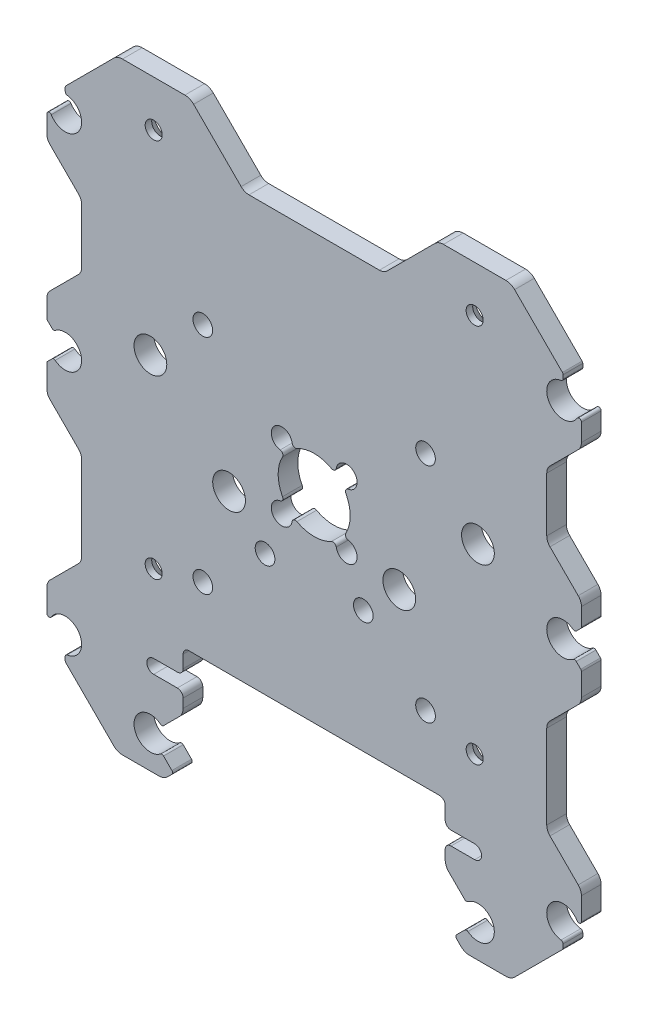
from build123d import *

# Parameters (mm, degrees)
BOSS_EXTRUDE1_DEPTH                            = 3
SKETCH2_W                                      = 21.308932188
SKETCH2_H                                      = 8.3
CUT_EXTRUDE1_DEPTH                             = 460.303275617
SKETCH3_W                                      = 5.3
SKETCH3_H                                      = 9.694178424
CUT_EXTRUDE2_DEPTH                             = 460.303275617
CUT_EXTRUDE3_DEPTH                             = 460.303275617
SKETCH5_W                                      = 5.3
SKETCH5_H                                      = 24.809178424
CUT_EXTRUDE4_DEPTH                             = 460.303275617
CUT_EXTRUDE5_DEPTH                             = 460.303275617
CUT_EXTRUDE6_DEPTH                             = 460.303275617
CUT_EXTRUDE7_DEPTH                             = 460.303275617
SKETCH9_W                                      = 5.3
SKETCH9_H                                      = 14.209178424
CUT_EXTRUDE8_DEPTH                             = 460.303275617
CUT_EXTRUDE9_DEPTH                             = 460.303275617
SKETCH11_W                                     = 5.3
SKETCH11_H                                     = 20.294178424
CUT_EXTRUDE10_DEPTH                            = 460.303275617
CUT_EXTRUDE11_DEPTH                            = 460.303275617
DRAFT1_ANGLE                                   = 45
DRAFT2_ANGLE                                   = 45
DRAFT3_ANGLE                                   = 45
DRAFT4_ANGLE                                   = 45
DRAFT5_ANGLE                                   = 45
DRAFT6_ANGLE                                   = 45
DRAFT7_ANGLE                                   = 45
DRAFT8_ANGLE                                   = 45
DRAFT9_ANGLE                                   = 45
SKETCH13_W                                     = 1.6
SKETCH13_H                                     = 3
SKETCH14_W                                     = 1.6
SKETCH14_H                                     = 3
SKETCH15_W                                     = 1.6
SKETCH15_H                                     = 3
SKETCH16_W                                     = 1.6
SKETCH16_H                                     = 3
SKETCH17_W                                     = 2.5
SKETCH17_H                                     = 3
SKETCH18_W                                     = 2.5
SKETCH18_H                                     = 3
CSK_FOR_M2_FLAT_HEAD_MACHINE_SCREW1_AT_2_COUNT = 2
CSK_FOR_M2_FLAT_HEAD_MACHINE_SCREW1_AT_2_PITCH = 49
CSK_FOR_M2_FLAT_HEAD_MACHINE_SCREW1_AT_3_COUNT = 2
CSK_FOR_M2_FLAT_HEAD_MACHINE_SCREW1_AT_3_PITCH = 75.927597091
CSK_FOR_M2_FLAT_HEAD_MACHINE_SCREW1_AT_4_COUNT = 2
CSK_FOR_M2_FLAT_HEAD_MACHINE_SCREW1_AT_4_PITCH = 58
F_3_0_3_DIAMETER_HOLE1_D                       = 3
F_5_0_5_DIAMETER_HOLE1_D                       = 5
FILLET1_R                                      = 0.36
FILLET2_R                                      = 0.89
FILLET3_R                                      = 1.69
FILLET4_R                                      = 1.89


with BuildPart() as part:
    # Sketch1 → Boss-Extrude1 (new body)
    with BuildSketch(Plane.XY.offset(3)):
        with BuildLine():
            Line((252.38239682, 372.890142644), (252.38239682, 373.92567655))
            Line((252.38239682, 373.92567655), (244.427930726, 381.880142644))
            Line((244.427930726, 381.880142644), (184.336862914, 381.880142644))
            Line((184.336862914, 381.880142644), (176.38239682, 373.92567655))
            Line((176.38239682, 373.92567655), (176.38239682, 372.890142645))
            ThreePointArc((176.38239682, 372.890142645), (178.563043816, 369.167531226), (174.249529687, 369.085965588))
            ThreePointArc((174.249529687, 369.085965588), (173.844846402, 369.244695355), (173.58239682, 368.898164092))
            Line((173.58239682, 368.898164092), (173.58239682, 302.862121197))
            ThreePointArc((173.58239682, 302.862121197), (173.844846402, 302.515589934), (174.249529687, 302.674319701))
            ThreePointArc((174.249529687, 302.674319701), (174.201749824, 300.147531226), (176.38239682, 298.870142644))
            Line((176.38239682, 298.870142644), (176.38239682, 297.834608739))
            Line((176.38239682, 297.834608739), (184.336862914, 289.880142644))
            Line((184.336862914, 289.880142644), (244.427930726, 289.880142644))
            Line((244.427930726, 289.880142644), (252.38239682, 297.834608739))
            Line((252.38239682, 297.834608739), (252.38239682, 298.870142644))
            ThreePointArc((252.38239682, 298.870142644), (250.201749824, 302.592754063), (254.515263953, 302.674319701))
            ThreePointArc((254.515263953, 302.674319701), (254.919947237, 302.515589934), (255.18239682, 302.862121197))
            Line((255.18239682, 302.862121197), (255.18239682, 368.898164092))
            ThreePointArc((255.18239682, 368.898164092), (254.919947237, 369.244695355), (254.515263953, 369.085965588))
            ThreePointArc((254.515263953, 369.085965588), (254.563043816, 371.612754063), (252.38239682, 372.890142644))
        make_face()
    extrude(amount=-BOSS_EXTRUDE1_DEPTH)

    # Sketch2 → Cut-Extrude1 (cut, through all)
    with BuildSketch(Plane(origin=(0, 0, 0), x_dir=(-1, 0, 0), z_dir=(0, 0, -1))):
        with Locations((-214.38239682, 377.730142644)):
            Rectangle(SKETCH2_W, SKETCH2_H)
    extrude(amount=-CUT_EXTRUDE1_DEPTH, mode=Mode.SUBTRACT)

    # Sketch3 → Cut-Extrude2 (cut, through all)
    with BuildSketch(Plane(origin=(0, 0, 0), x_dir=(-1, 0, 0), z_dir=(0, 0, -1))):
        with Locations((-176.23239682, 355.36871181)):
            Rectangle(SKETCH3_W, SKETCH3_H)
    extrude(amount=-CUT_EXTRUDE2_DEPTH, mode=Mode.SUBTRACT)

    # Sketch4 → Cut-Extrude3 (cut, through all)
    with BuildSketch(Plane(origin=(0, 0, 0), x_dir=(-1, 0, 0), z_dir=(0, 0, -1))):
        Polygon((-173.58239682, 336.090142644), (-173.58239682, 341.690142644), (-179.18239682, 336.090142644), align=None)
    extrude(amount=-CUT_EXTRUDE3_DEPTH, mode=Mode.SUBTRACT)

    # Sketch5 → Cut-Extrude4 (cut, through all)
    with BuildSketch(Plane(origin=(0, 0, 0), x_dir=(-1, 0, 0), z_dir=(0, 0, -1))):
        with Locations((-176.23239682, 319.401573479)):
            Rectangle(SKETCH5_W, SKETCH5_H)
    extrude(amount=-CUT_EXTRUDE4_DEPTH, mode=Mode.SUBTRACT)

    # Sketch6 → Cut-Extrude5 (cut, through all)
    with BuildSketch(Plane(origin=(0, 0, 0), x_dir=(-1, 0, 0), z_dir=(0, 0, -1))):
        Polygon((-237.311329008, 289.880142644), (-191.453464632, 289.880142644), (-192.917930726, 291.344608739), (-184.38239682, 299.880142644), (-194.38239682, 299.880142644), (-194.38239682, 308.729366667), (-234.38239682, 308.729366667), (-234.38239682, 299.880142644), (-244.38239682, 299.880142644), (-235.846862914, 291.344608739), align=None)
    extrude(amount=-CUT_EXTRUDE5_DEPTH, mode=Mode.SUBTRACT)

    # Sketch7 → Cut-Extrude6 (cut, through all)
    with BuildSketch(Plane(origin=(0, 0, 0), x_dir=(-1, 0, 0), z_dir=(0, 0, -1))):
        with BuildLine():
            Line((-194.38239682, 305.020142644), (-194.38239682, 302.920142644))
            Line((-194.38239682, 302.920142644), (-189.88239682, 302.920142644))
            ThreePointArc((-189.88239682, 302.920142644), (-188.83239682, 303.970142644), (-189.88239682, 305.020142644))
            Line((-189.88239682, 305.020142644), (-194.38239682, 305.020142644))
        make_face()
    extrude(amount=-CUT_EXTRUDE6_DEPTH, mode=Mode.SUBTRACT)

    # Sketch8 → Cut-Extrude7 (cut, through all)
    with BuildSketch(Plane(origin=(0, 0, 0), x_dir=(-1, 0, 0), z_dir=(0, 0, -1))):
        with BuildLine():
            Line((-234.38239682, 302.920142644), (-234.38239682, 305.020142644))
            Line((-234.38239682, 305.020142644), (-238.88239682, 305.020142644))
            ThreePointArc((-238.88239682, 305.020142644), (-239.93239682, 303.970142644), (-238.88239682, 302.920142644))
            Line((-238.88239682, 302.920142644), (-234.38239682, 302.920142644))
        make_face()
    extrude(amount=-CUT_EXTRUDE7_DEPTH, mode=Mode.SUBTRACT)

    # Sketch9 → Cut-Extrude8 (cut, through all)
    with BuildSketch(Plane(origin=(0, 0, 0), x_dir=(-1, 0, 0), z_dir=(0, 0, -1))):
        with Locations((-252.53239682, 319.401573479)):
            Rectangle(SKETCH9_W, SKETCH9_H)
    extrude(amount=-CUT_EXTRUDE8_DEPTH, mode=Mode.SUBTRACT)

    # Sketch10 → Cut-Extrude9 (cut, through all)
    with BuildSketch(Plane(origin=(0, 0, 0), x_dir=(-1, 0, 0), z_dir=(0, 0, -1))):
        Polygon((-255.18239682, 341.690142644), (-255.18239682, 336.090142644), (-249.58239682, 341.690142644), align=None)
    extrude(amount=-CUT_EXTRUDE9_DEPTH, mode=Mode.SUBTRACT)

    # Sketch11 → Cut-Extrude10 (cut, through all)
    with BuildSketch(Plane(origin=(0, 0, 0), x_dir=(-1, 0, 0), z_dir=(0, 0, -1))):
        with Locations((-252.53239682, 355.36871181)):
            Rectangle(SKETCH11_W, SKETCH11_H)
    extrude(amount=-CUT_EXTRUDE10_DEPTH, mode=Mode.SUBTRACT)

    # Sketch12 → Cut-Extrude11 (cut, through all)
    with BuildSketch(Plane(origin=(0, 0, 0), x_dir=(-1, 0, 0), z_dir=(0, 0, -1))):
        with BuildLine():
            ThreePointArc((-219.210456442, 341.509500305), (-219.88239682, 338.875142644), (-219.210456442, 336.240784984))
            ThreePointArc((-219.210456442, 336.240784984), (-219.201307991, 335.779397988), (-219.573840458, 335.507035701))
            ThreePointArc((-219.573840458, 335.507035701), (-218.200772024, 335.05676744), (-217.750503763, 333.683699006))
            ThreePointArc((-217.750503763, 333.683699006), (-217.478141477, 334.056231474), (-217.01675448, 334.047083022))
            ThreePointArc((-217.01675448, 334.047083022), (-214.38239682, 333.375142644), (-211.748039159, 334.047083022))
            ThreePointArc((-211.748039159, 334.047083022), (-211.286652163, 334.056231474), (-211.014289877, 333.683699006))
            ThreePointArc((-211.014289877, 333.683699006), (-210.564021616, 335.05676744), (-209.190953182, 335.507035701))
            ThreePointArc((-209.190953182, 335.507035701), (-209.563485649, 335.779397988), (-209.554337198, 336.240784984))
            ThreePointArc((-209.554337198, 336.240784984), (-208.88239682, 338.875142644), (-209.554337198, 341.509500305))
            ThreePointArc((-209.554337198, 341.509500305), (-209.563485649, 341.970887301), (-209.190953182, 342.243249587))
            ThreePointArc((-209.190953182, 342.243249587), (-210.564021616, 342.693517849), (-211.014289877, 344.066586283))
            ThreePointArc((-211.014289877, 344.066586283), (-211.286652163, 343.694053815), (-211.748039159, 343.703202267))
            ThreePointArc((-211.748039159, 343.703202267), (-214.38239682, 344.375142644), (-217.01675448, 343.703202267))
            ThreePointArc((-217.01675448, 343.703202267), (-217.478141477, 343.694053815), (-217.750503763, 344.066586283))
            ThreePointArc((-217.750503763, 344.066586283), (-218.200772024, 342.693517849), (-219.573840458, 342.243249587))
            ThreePointArc((-219.573840458, 342.243249587), (-219.201307991, 341.970887301), (-219.210456442, 341.509500305))
        make_face()
    extrude(amount=-CUT_EXTRUDE11_DEPTH, mode=Mode.SUBTRACT)

    # Draft1
    draft1_faces = [part.faces().sort_by_distance(p)[0] for p in [
        (252.53239682, 365.515801022, 1.5),
    ]]
    draft(draft1_faces, Plane(origin=(255.18239682, 302.862121197, 0), x_dir=(0, 1, 0), z_dir=(1, 0, 0)), DRAFT1_ANGLE)

    # Draft2
    draft2_faces = [part.faces().sort_by_distance(p)[0] for p in [
        (239.38239682, 299.880142644, 1.5),
    ]]
    draft(draft2_faces, Plane(origin=(234.38239682, 308.729366667, 3), x_dir=(0, 0, -1), z_dir=(-1, 0, 0)), DRAFT2_ANGLE)

    # Draft3
    draft3_faces = [part.faces().sort_by_distance(p)[0] for p in [
        (189.38239682, 299.880142644, 1.5),
    ]]
    draft(draft3_faces, Plane(origin=(194.38239682, 299.880142644, 3), x_dir=(0, 0, 1), z_dir=(1, 0, 0)), DRAFT3_ANGLE)

    # Draft4
    draft4_faces = [part.faces().sort_by_distance(p)[0] for p in [
        (176.23239682, 306.996984267, 1.5),
    ]]
    draft(draft4_faces, Plane(origin=(173.58239682, 368.898164092, 0), x_dir=(0, 0, -1), z_dir=(-1, 0, 0)), DRAFT4_ANGLE)

    # Draft5
    draft5_faces = [part.faces().sort_by_distance(p)[0] for p in [
        (252.38239682, 341.690142644, 1.5),
        (252.53239682, 345.221622598, 1.5),
    ]]
    draft(draft5_faces, Plane(origin=(255.18239682, 302.862121197, 0), x_dir=(0, 1, 0), z_dir=(1, 0, 0)), DRAFT5_ANGLE)

    # Draft6
    draft6_faces = [part.faces().sort_by_distance(p)[0] for p in [
        (252.53239682, 312.296984267, 1.5),
        (252.53239682, 326.506162691, 1.5),
    ]]
    draft(draft6_faces, Plane(origin=(249.88239682, 312.296984267, 3), x_dir=(0, 1, 0), z_dir=(1, 0, 0)), DRAFT6_ANGLE)

    # Draft7
    draft7_faces = [part.faces().sort_by_distance(p)[0] for p in [
        (176.38239682, 336.090142644, 1.5),
        (176.23239682, 331.806162691, 1.5),
    ]]
    draft(draft7_faces, Plane(origin=(173.58239682, 368.898164092, 0), x_dir=(0, 0, -1), z_dir=(-1, 0, 0)), DRAFT7_ANGLE)

    # Draft8
    draft8_faces = [part.faces().sort_by_distance(p)[0] for p in [
        (176.23239682, 360.215801022, 1.5),
        (176.23239682, 350.521622598, 1.5),
    ]]
    draft(draft8_faces, Plane(origin=(178.88239682, 360.215801022, 3), x_dir=(0, 0, -1), z_dir=(-1, 0, 0)), DRAFT8_ANGLE)

    # Draft9
    draft9_faces = [part.faces().sort_by_distance(p)[0] for p in [
        (225.036862914, 377.730142644, 1.5),
        (203.727930726, 377.730142644, 1.5),
    ]]
    draft(draft9_faces, Plane(origin=(225.036862914, 373.580142644, 3), x_dir=(0, 0, 1), z_dir=(0, 1, 0)), DRAFT9_ANGLE)

    # Sketch13 → Cut-Revolve1 (revolve, cut)
    with BuildSketch(Plane(origin=(0, 343.824888699, 0), x_dir=(1, 0, 0), z_dir=(0, 1, 0))):
        with Locations((210.232650766, -1.5)):
            Rectangle(SKETCH13_W, SKETCH13_H)
    revolve(axis=Axis((209.432650766, 343.824888699, 0), (0, 0, 1)), mode=Mode.SUBTRACT)

    # Sketch14 → Cut-Revolve2 (revolve, cut)
    with BuildSketch(Plane(origin=(0, 333.92539659, 0), x_dir=(1, 0, 0), z_dir=(0, 1, 0))):
        with Locations((210.232650766, -1.5)):
            Rectangle(SKETCH14_W, SKETCH14_H)
    revolve(axis=Axis((209.432650766, 333.92539659, 0), (0, 0, 1)), mode=Mode.SUBTRACT)

    # Sketch15 → Cut-Revolve3 (revolve, cut)
    with BuildSketch(Plane(origin=(0, 333.92539659, 0), x_dir=(1, 0, 0), z_dir=(0, 1, 0))):
        with Locations((220.132142874, -1.5)):
            Rectangle(SKETCH15_W, SKETCH15_H)
    revolve(axis=Axis((219.332142874, 333.92539659, 0), (0, 0, 1)), mode=Mode.SUBTRACT)

    # Sketch16 → Cut-Revolve4 (revolve, cut)
    with BuildSketch(Plane(origin=(0, 343.824888699, 0), x_dir=(1, 0, 0), z_dir=(0, 1, 0))):
        with Locations((220.132142874, -1.5)):
            Rectangle(SKETCH16_W, SKETCH16_H)
    revolve(axis=Axis((219.332142874, 343.824888699, 0), (0, 0, 1)), mode=Mode.SUBTRACT)

    # Sketch17 → Cut-Revolve5 (revolve, cut)
    with BuildSketch(Plane(origin=(0, 370.390142644, 0), x_dir=(1, 0, 0), z_dir=(0, 1, 0))):
        with Locations((253.63239682, -1.5)):
            Rectangle(SKETCH17_W, SKETCH17_H)
    revolve(axis=Axis((252.38239682, 370.390142644, 0), (0, 0, 1)), mode=Mode.SUBTRACT)

    # Sketch18 → Cut-Revolve6 (revolve, cut)
    with BuildSketch(Plane(origin=(0, 301.370142644, 0), x_dir=(1, 0, 0), z_dir=(0, 1, 0))):
        with Locations((177.63239682, -1.5)):
            Rectangle(SKETCH18_W, SKETCH18_H)
    revolve(axis=Axis((176.38239682, 301.370142644, 0), (0, 0, 1)), mode=Mode.SUBTRACT)

    # Sketch19 → CSK for M2 Flat Head Machine Screw1 (revolve, cut)
    with BuildSketch(Plane(origin=(238.88239682, 316.880142644, 0), x_dir=(0, 1, 0), z_dir=(1, 0, 0))):
        Polygon((0, 0), (0, 3), (1.3, 3), (1.3, 2), (3.3, 0), align=None)
    csk_for_m2_flat_head_machine_screw1 = revolve(axis=Axis((238.88239682, 316.880142644, -6.35), (0, 0, 1)), mode=Mode.SUBTRACT)

    # CSK for M2 Flat Head Machine Screw1 at 2: CSK for M2 Flat Head Machine Screw1 ×2
    with Locations(*[(-i * CSK_FOR_M2_FLAT_HEAD_MACHINE_SCREW1_AT_2_PITCH, 0, 0) for i in range(1, CSK_FOR_M2_FLAT_HEAD_MACHINE_SCREW1_AT_2_COUNT)]):
        add(csk_for_m2_flat_head_machine_screw1, mode=Mode.SUBTRACT)

    # CSK for M2 Flat Head Machine Screw1 at 3: CSK for M2 Flat Head Machine Screw1 ×2
    with Locations(*[Vector(-0.6453516491682096, 0.7638856255460448, 0) * (i * CSK_FOR_M2_FLAT_HEAD_MACHINE_SCREW1_AT_3_PITCH) for i in range(1, CSK_FOR_M2_FLAT_HEAD_MACHINE_SCREW1_AT_3_COUNT)]):
        add(csk_for_m2_flat_head_machine_screw1, mode=Mode.SUBTRACT)

    # CSK for M2 Flat Head Machine Screw1 at 4: CSK for M2 Flat Head Machine Screw1 ×2
    with Locations(*[(0, i * CSK_FOR_M2_FLAT_HEAD_MACHINE_SCREW1_AT_4_PITCH, 0) for i in range(1, CSK_FOR_M2_FLAT_HEAD_MACHINE_SCREW1_AT_4_COUNT)]):
        add(csk_for_m2_flat_head_machine_screw1, mode=Mode.SUBTRACT)

    # Ø3.0 (3) Diameter Hole1 (through all)
    with Locations(Plane.XY.offset(3)):
        with Locations((206.88239682, 327.380142644), (221.88239682, 327.380142644), (197.38239682, 352.880142644), (231.38239682, 318.880142644), (231.38239682, 352.880142644), (197.38239682, 318.880142644)):
            Hole(F_3_0_3_DIAMETER_HOLE1_D / 2)

    # Ø5.0 (5) Diameter Hole1 (through all)
    with Locations(Plane.XY.offset(3)):
        with Locations((176.38239682, 338.890142644), (189.38239682, 294.880142644), (239.38239682, 294.880142644), (252.38239682, 338.890142644), (227.37239682, 332.870142644), (189.38239682, 344.880142644), (239.38239682, 344.880142644), (201.39239682, 332.870142644)):
            Hole(F_5_0_5_DIAMETER_HOLE1_D / 2)

    # Fillet1
    fillet1_edges = [part.edges().sort_by_distance(p)[0] for p in [
        (176.38239682, 298.870142644, 1.5),
        (255.18239682, 341.690142644, 1.5),
        (252.38239682, 298.870142644, 1.5),
        (176.38239682, 297.834608739, 1.5),
        (191.150163773, 296.647909597, 1.5),
        (174.614629867, 340.657909597, 1.5),
        (252.38239682, 297.834608739, 1.5),
        (173.58239682, 336.090142644, 1.5),
        (176.38239682, 372.890142645, 1.5),
        (254.150163773, 337.122375691, 1.5),
        (174.614629867, 337.122375691, 1.5),
        (252.38239682, 373.92567655, 1.5),
        (255.18239682, 336.090142644, 1.5),
        (237.614629867, 296.647909597, 1.5),
        (254.150163773, 340.657909597, 1.5),
        (237.614629867, 293.112375691, 1.5),
        (176.38239682, 373.92567655, 1.5),
        (235.846862914, 291.344608739, 1.5),
        (173.58239682, 341.690142644, 1.5),
        (192.917930726, 291.344608739, 1.5),
        (252.38239682, 372.890142644, 1.5),
        (191.150163773, 293.112375691, 1.5),
    ]]
    fillet(fillet1_edges, radius=FILLET1_R)

    # Fillet2
    fillet2_edges = [part.edges().sort_by_distance(p)[0] for p in [
        (194.38239682, 308.729366667, 1.5),
        (234.38239682, 305.020142644, 1.5),
        (234.38239682, 308.729366667, 1.5),
        (194.38239682, 302.920142644, 1.5),
        (194.38239682, 305.020142644, 1.5),
        (234.38239682, 302.920142644, 1.5),
    ]]
    fillet(fillet2_edges, radius=FILLET2_R)

    # Fillet3
    fillet3_edges = [part.edges().sort_by_distance(p)[0] for p in [
        (249.88239682, 350.521622598, 1.5),
        (225.036862914, 373.580142644, 1.5),
        (178.88239682, 360.215801022, 1.5),
        (255.18239682, 306.996984267, 1.5),
        (173.58239682, 365.515801022, 1.5),
        (249.88239682, 326.506162691, 1.5),
        (255.18239682, 365.515801022, 1.5),
        (255.18239682, 345.221622598, 1.5),
        (178.88239682, 350.521622598, 1.5),
        (173.58239682, 306.996984267, 1.5),
        (203.727930726, 373.580142644, 1.5),
        (173.58239682, 345.221622598, 1.5),
        (249.88239682, 312.296984267, 1.5),
        (173.58239682, 331.806162691, 1.5),
        (255.18239682, 331.806162691, 1.5),
        (178.88239682, 326.506162691, 1.5),
        (178.88239682, 312.296984267, 1.5),
        (249.88239682, 360.215801022, 1.5),
    ]]
    fillet(fillet3_edges, radius=FILLET3_R)

    # Fillet4
    fillet4_edges = [part.edges().sort_by_distance(p)[0] for p in [
        (191.453464632, 289.880142644, 1.5),
        (237.311329008, 289.880142644, 1.5),
        (234.38239682, 299.880142644, 1.5),
        (244.427930726, 381.880142644, 1.5),
        (184.336862914, 289.880142644, 1.5),
        (233.336862914, 381.880142644, 1.5),
        (194.38239682, 299.880142644, 1.5),
        (195.427930726, 381.880142644, 1.5),
        (184.336862914, 381.880142644, 1.5),
        (244.427930726, 289.880142644, 1.5),
    ]]
    fillet(fillet4_edges, radius=FILLET4_R)


solid = part.part
